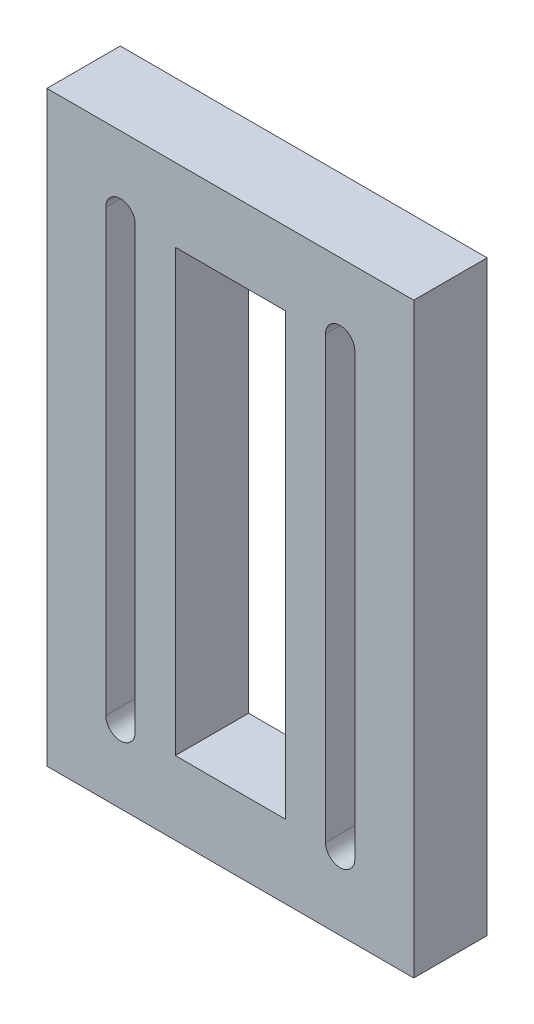
from build123d import *

# Parameters (mm, degrees)
ESQUISSE1_W        = 50
ESQUISSE1_H        = 80
BOSS_EXTRU_1_DEPTH = 10


with BuildPart() as part:
    # Esquisse1 → Boss.-Extru.1 (new body)
    with BuildSketch(Plane.XY):
        with Locations((3.064709519, 0)):
            Rectangle(ESQUISSE1_W, ESQUISSE1_H)
        with BuildLine():
            Line((-13.904077664, -30), (-13.904077664, 30))
            ThreePointArc((-13.904077664, 30), (-11.904077664, 32), (-9.904077664, 30))
            Line((-9.904077664, 30), (-9.904077664, -30))
            ThreePointArc((-9.904077664, -30), (-11.904077664, -32), (-13.904077664, -30))
        make_face(mode=Mode.SUBTRACT)
        Polygon((-4.435290481, -30), (-4.435290481, 0), (-4.435290481, 30), (10.564709519, 30), (10.564709519, 0), (10.564709519, -30), align=None, mode=Mode.SUBTRACT)
        with BuildLine():
            Line((16.033496703, -30), (16.033496703, 30))
            ThreePointArc((16.033496703, 30), (18.033496703, 32), (20.033496703, 30))
            Line((20.033496703, 30), (20.033496703, -30))
            ThreePointArc((20.033496703, -30), (18.033496703, -32), (16.033496703, -30))
        make_face(mode=Mode.SUBTRACT)
    extrude(amount=BOSS_EXTRU_1_DEPTH)


solid = part.part
